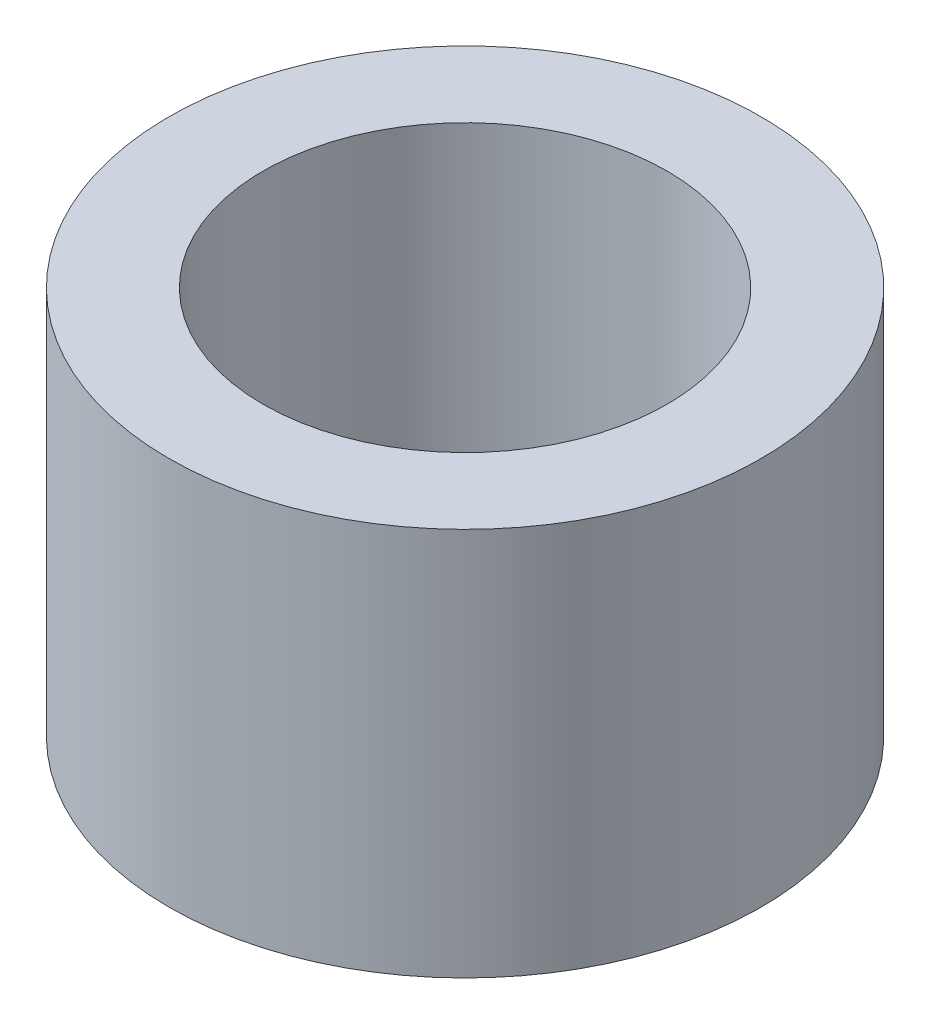
from build123d import *

# Parameters (mm, degrees)
SKETCH1_R           = 3.81
SKETCH1_R_2         = 2.6
BOSS_EXTRUDE1_DEPTH = 5


with BuildPart() as part:
    # Sketch1 → Boss-Extrude1 (new body)
    with BuildSketch(Plane(origin=(0, 0, 0), x_dir=(1, 0, 0), z_dir=(0, 1, 0))):
        Circle(SKETCH1_R)
        Circle(SKETCH1_R_2, mode=Mode.SUBTRACT)
    extrude(amount=BOSS_EXTRUDE1_DEPTH)


solid = part.part
